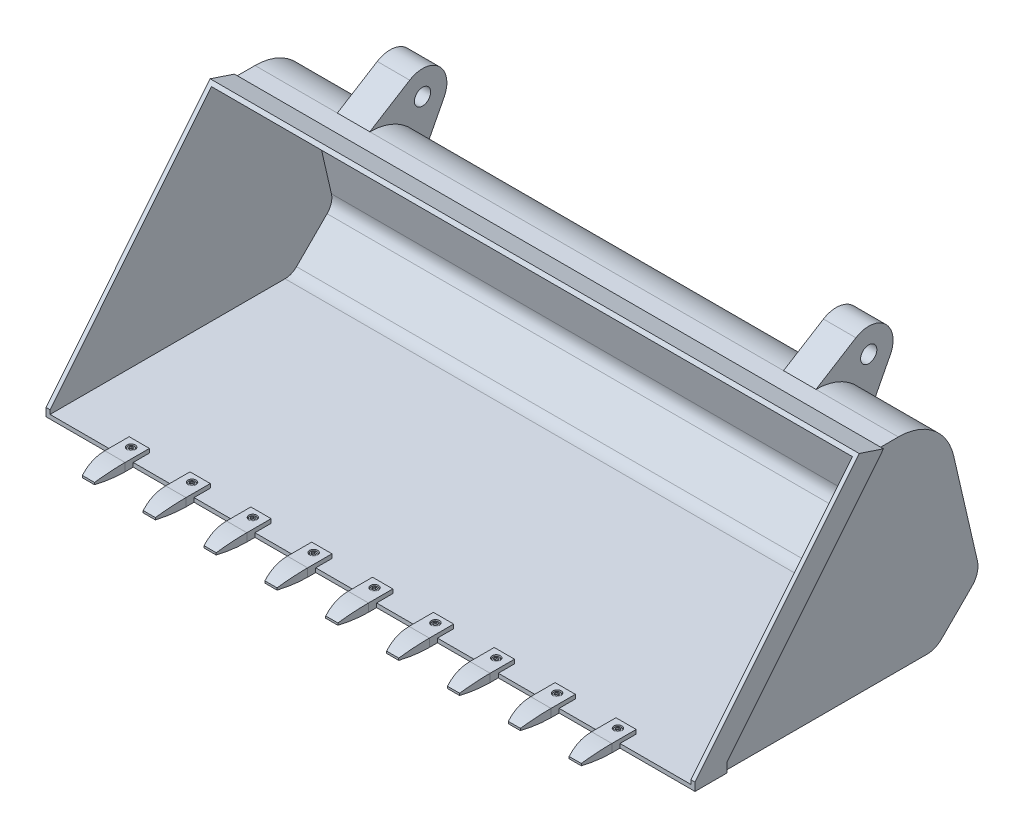
from build123d import *

# Parameters (mm, degrees)
BOSS_EXTRUDE1_DEPTH = 800
SHELL1_T            = -10
CUT_EXTRUDE2_REACH  = 706.648
SKETCH4_W           = 1580
SKETCH4_H           = 34
CUT_EXTRUDE3_DEPTH  = 7
SKETCH6_R           = 20
BOSS_EXTRUDE2_DEPTH = 80
BOSS_EXTRUDE3_DEPTH = 25
SKETCH8_R           = 6
CUT_EXTRUDE4_DEPTH  = 21
SKETCH9_R           = 10
CUT_EXTRUDE5_DEPTH  = 10
SKETCH10_R          = 8.5
BOSS_EXTRUDE4_DEPTH = 8
FILLET1_R           = 1
SKETCH11_R          = 6
BOSS_EXTRUDE5_DEPTH = 8
CUT_EXTRUDE6_DEPTH  = 4
CUT_EXTRUDE8_DEPTH  = 570.349576998
LPATTERN3_COUNT     = 9
LPATTERN3_PITCH     = 150


with BuildPart() as part:
    # Sketch1 → Boss-Extrude1 (new body, symmetric)
    with BuildSketch(Plane(origin=(0, 0, 0), x_dir=(0, 0, -1), z_dir=(1, 0, 0))):
        with BuildLine():
            Line((-289.644660941, 0), (289.644660941, 0))
            ThreePointArc((289.644660941, 0), (308.778832559, 3.806023374), (325, 14.644660941))
            Line((325, 14.644660941), (400.359105685, 90.003766626))
            ThreePointArc((400.359105685, 90.003766626), (413.066851423, 111.577237895), (413.722269865, 136.606658403))
            Line((413.722269865, 136.606658403), (355.027249142, 390.842724606))
            ThreePointArc((355.027249142, 390.842724606), (305.767489201, 468.914718957), (218.615440072, 499.349576998))
            Line((218.615440072, 499.349576998), (174.976468406, 499.349576998))
            Line((174.976468406, 499.349576998), (114.976468406, 519.349576998))
            Line((114.976468406, 519.349576998), (-289.644660941, 20))
            Line((-289.644660941, 20), (-289.644660941, 0))
        make_face()
    extrude(amount=BOSS_EXTRUDE1_DEPTH, both=True)

    # Shell1
    shell1_openings = [part.faces().sort_by_distance(p)[0] for p in [
        (0, 269.674788499, 87.334096267),
    ]]
    offset(amount=SHELL1_T, openings=shell1_openings, kind=Kind.INTERSECTION)

    # Sketch4 → Cut-Extrude2 (cut, up to next)
    with BuildSketch(Plane.XY.offset(289.644660941), mode=Mode.PRIVATE) as cut_extrude2_sk1:
        with Locations((0, 27)):
            Rectangle(SKETCH4_W, SKETCH4_H)
    cut_extrude2_tool1 = extrude(cut_extrude2_sk1.sketch, amount=-CUT_EXTRUDE2_REACH, mode=Mode.PRIVATE) & part.part
    add(cut_extrude2_tool1.solids().sort_by_distance((0, 27, 289.644661))[0], mode=Mode.SUBTRACT)

    # Sketch5 → Cut-Extrude3 (cut)
    with BuildSketch(Plane(origin=(800, 0, 0), x_dir=(0, 0, -1), z_dir=(1, 0, 0))):
        with BuildLine():
            Line((325, 14.644660941), (400.359105685, 90.003766626))
            ThreePointArc((400.359105685, 90.003766626), (413.066851423, 111.577237895), (413.722269865, 136.606658403))
            Line((413.722269865, 136.606658403), (355.027249142, 390.842724606))
            ThreePointArc((355.027249142, 390.842724606), (305.767489201, 468.914718957), (218.615440072, 499.349576998))
            Line((218.615440072, 499.349576998), (174.976468406, 499.349576998))
            Line((174.976468406, 499.349576998), (-210.355339059, 23.80526874))
            Line((-210.355339059, 23.80526874), (-210.355339059, 0))
            Line((-210.355339059, 0), (289.644660941, 0))
            ThreePointArc((289.644660941, 0), (308.778832559, 3.806023374), (325, 14.644660941))
        make_face()
    cut_extrude3 = extrude(amount=-CUT_EXTRUDE3_DEPTH, mode=Mode.SUBTRACT)

    # Sketch6 → Boss-Extrude2 (add)
    with BuildSketch(Plane(origin=(590, 0, 0), x_dir=(0, 0, -1), z_dir=(1, 0, 0))):
        with BuildLine():
            Line((218.615440072, 499.349576998), (317.000438812, 560.344593376))
            ThreePointArc((317.000438812, 560.344593376), (389.333575484, 553.41808558), (401.94611096, 481.857040871))
            Line((401.94611096, 481.857040871), (355.027249142, 390.842724606))
            ThreePointArc((355.027249142, 390.842724606), (305.767489201, 468.914718957), (218.615440072, 499.349576998))
        make_face()
        with Locations((348.615440072, 509.349576998)):
            Circle(SKETCH6_R, mode=Mode.SUBTRACT)
    boss_extrude2 = extrude(amount=-BOSS_EXTRUDE2_DEPTH)

    # Mirror1: Cut-Extrude3, Boss-Extrude2 across plane
    add(cut_extrude3.mirror(Plane(origin=(0, 0, 0), x_dir=(0, 0, 1), z_dir=(1, 0, 0))), mode=Mode.SUBTRACT)
    add(boss_extrude2.mirror(Plane(origin=(0, 0, 0), x_dir=(0, 0, 1), z_dir=(1, 0, 0))))


with BuildPart() as body_2:
    # Sketch7 → Boss-Extrude3 (new body, symmetric)
    with BuildSketch(Plane(origin=(590, 0, 0), x_dir=(0, 0, -1), z_dir=(1, 0, 0))):
        with BuildLine():
            Line((-249.644660941, 20), (-249.644660941, 10))
            Line((-249.644660941, 10), (-289.644660941, 10))
            Line((-289.644660941, 10), (-289.644660941, 0))
            Line((-289.644660941, 0), (-375.028145094, 0))
            Line((-375.028145094, 0), (-375.028145094, 5))
            ThreePointArc((-375.028145094, 5), (-343.185680603, 16.201915172), (-309.644660941, 20))
            Line((-309.644660941, 20), (-249.644660941, 20))
        make_face()
    extrude(amount=BOSS_EXTRUDE3_DEPTH, both=True)


with BuildPart() as cut_extrude4_tool:
    # Sketch8 → Cut-Extrude4 (new body, through all)
    with BuildSketch(Plane(origin=(0, 20, 0), x_dir=(1, 0, 0), z_dir=(0, 1, 0))):
        with Locations((590, -269.644660941)):
            Circle(SKETCH8_R)
    extrude(amount=-CUT_EXTRUDE4_DEPTH)


with BuildPart() as part_1:
    add(part.part)

    # Cut-Extrude4: cut by cut_extrude4_tool
    add(cut_extrude4_tool.part, mode=Mode.SUBTRACT)


with BuildPart() as body_2_1:
    add(body_2.part)

    # Cut-Extrude4: cut by cut_extrude4_tool
    add(cut_extrude4_tool.part, mode=Mode.SUBTRACT)

    # Sketch9 → Cut-Extrude5 (cut)
    with BuildSketch(Plane(origin=(0, 20, 0), x_dir=(1, 0, 0), z_dir=(0, 1, 0))):
        with Locations((590, -269.644660941)):
            Circle(SKETCH9_R)
    extrude(amount=-CUT_EXTRUDE5_DEPTH, mode=Mode.SUBTRACT)

    # Sketch13 → Cut-Extrude8 (cut, through all)
    with BuildSketch(Plane.XZ):
        with BuildLine():
            Line((615, 309.644660941), (636.074420872, 309.644660941))
            Line((636.074420872, 309.644660941), (636.074420872, 389.099553397))
            Line((636.074420872, 389.099553397), (538.954907842, 389.099553397))
            Line((538.954907842, 389.099553397), (538.954907842, 309.644660941))
            Line((538.954907842, 309.644660941), (565, 309.644660941))
            ThreePointArc((565, 309.644660941), (567.51445135, 342.716552329), (575, 375.028145094))
            Line((575, 375.028145094), (605, 375.028145094))
            ThreePointArc((605, 375.028145094), (612.48554865, 342.716552329), (615, 309.644660941))
        make_face()
    extrude(amount=-CUT_EXTRUDE8_DEPTH, mode=Mode.SUBTRACT)


with BuildPart() as body_3:
    # Sketch10 → Boss-Extrude4 (new body)
    with BuildSketch(Plane(origin=(0, 10, 0), x_dir=(1, 0, 0), z_dir=(0, 1, 0))):
        with Locations((590, -269.644660941)):
            Circle(SKETCH10_R)
    extrude(amount=BOSS_EXTRUDE4_DEPTH)

    # Fillet1
    fillet1_edges = [body_3.edges().sort_by_distance(p)[0] for p in [
        (581.5, 18, 269.644660941),
    ]]
    fillet(fillet1_edges, radius=FILLET1_R)

    # Sketch12 → Cut-Extrude6 (cut)
    with BuildSketch(Plane(origin=(0, 18, 0), x_dir=(1, 0, 0), z_dir=(0, 1, 0))):
        Polygon((592.75, -264.88152122), (587.25, -264.88152122), (584.5, -269.644660941), (587.25, -274.407800661), (592.75, -274.407800661), (595.5, -269.644660941), align=None)
    extrude(amount=-CUT_EXTRUDE6_DEPTH, mode=Mode.SUBTRACT)


with BuildPart() as body_4:
    # Sketch11 → Boss-Extrude5 (new body)
    with BuildSketch(Plane(origin=(0, 10, 0), x_dir=(1, 0, 0), z_dir=(0, 1, 0))):
        with Locations((590, -269.644660941)):
            Circle(SKETCH11_R)
    extrude(amount=-BOSS_EXTRUDE5_DEPTH)


with BuildPart() as lpattern3_1:
    # LPattern3: pattern copy
    add(body_3.part.moved(Location(Vector(-1, 0, 0) * (1 * LPATTERN3_PITCH))))


with BuildPart() as lpattern3_2:
    # LPattern3: pattern copy
    add(body_3.part.moved(Location(Vector(-1, 0, 0) * (2 * LPATTERN3_PITCH))))


with BuildPart() as lpattern3_3:
    # LPattern3: pattern copy
    add(body_3.part.moved(Location(Vector(-1, 0, 0) * (3 * LPATTERN3_PITCH))))


with BuildPart() as lpattern3_4:
    # LPattern3: pattern copy
    add(body_3.part.moved(Location(Vector(-1, 0, 0) * (4 * LPATTERN3_PITCH))))


with BuildPart() as lpattern3_5:
    # LPattern3: pattern copy
    add(body_3.part.moved(Location(Vector(-1, 0, 0) * (5 * LPATTERN3_PITCH))))


with BuildPart() as lpattern3_6:
    # LPattern3: pattern copy
    add(body_3.part.moved(Location(Vector(-1, 0, 0) * (6 * LPATTERN3_PITCH))))


with BuildPart() as lpattern3_7:
    # LPattern3: pattern copy
    add(body_3.part.moved(Location(Vector(-1, 0, 0) * (7 * LPATTERN3_PITCH))))


with BuildPart() as lpattern3_8:
    # LPattern3: pattern copy
    add(body_3.part.moved(Location(Vector(-1, 0, 0) * (8 * LPATTERN3_PITCH))))


with BuildPart() as lpattern3_9:
    # LPattern3: pattern copy
    add(body_2_1.part.moved(Location(Vector(-1, 0, 0) * (1 * LPATTERN3_PITCH))))


with BuildPart() as lpattern3_10:
    # LPattern3: pattern copy
    add(body_2_1.part.moved(Location(Vector(-1, 0, 0) * (2 * LPATTERN3_PITCH))))


with BuildPart() as lpattern3_11:
    # LPattern3: pattern copy
    add(body_2_1.part.moved(Location(Vector(-1, 0, 0) * (3 * LPATTERN3_PITCH))))


with BuildPart() as lpattern3_12:
    # LPattern3: pattern copy
    add(body_2_1.part.moved(Location(Vector(-1, 0, 0) * (4 * LPATTERN3_PITCH))))


with BuildPart() as lpattern3_13:
    # LPattern3: pattern copy
    add(body_2_1.part.moved(Location(Vector(-1, 0, 0) * (5 * LPATTERN3_PITCH))))


with BuildPart() as lpattern3_14:
    # LPattern3: pattern copy
    add(body_2_1.part.moved(Location(Vector(-1, 0, 0) * (6 * LPATTERN3_PITCH))))


with BuildPart() as lpattern3_15:
    # LPattern3: pattern copy
    add(body_2_1.part.moved(Location(Vector(-1, 0, 0) * (7 * LPATTERN3_PITCH))))


with BuildPart() as lpattern3_16:
    # LPattern3: pattern copy
    add(body_2_1.part.moved(Location(Vector(-1, 0, 0) * (8 * LPATTERN3_PITCH))))


solid = Compound([part_1.part, body_2_1.part, body_3.part, body_4.part, lpattern3_1.part, lpattern3_2.part, lpattern3_3.part, lpattern3_4.part, lpattern3_5.part, lpattern3_6.part, lpattern3_7.part, lpattern3_8.part, lpattern3_9.part, lpattern3_10.part, lpattern3_11.part, lpattern3_12.part, lpattern3_13.part, lpattern3_14.part, lpattern3_15.part, lpattern3_16.part])
